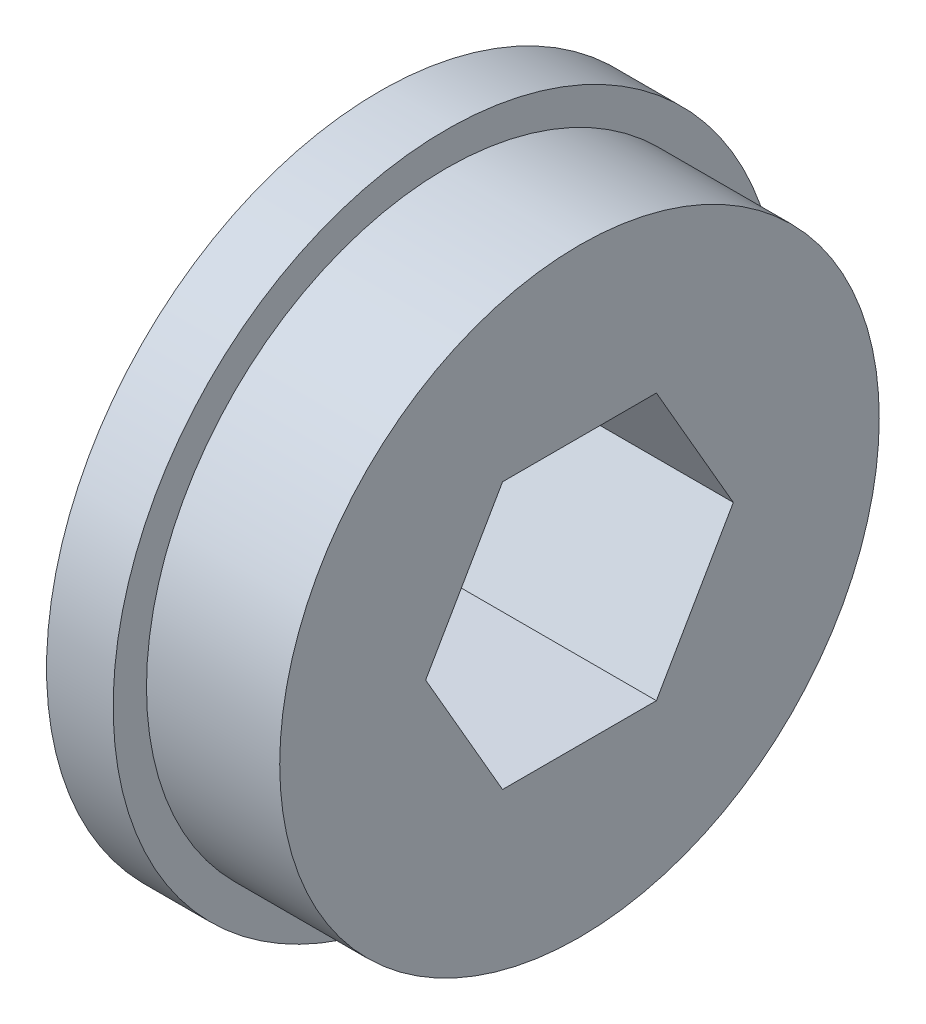
from build123d import *

# Parameters (mm, degrees)
SKETCH1_R           = 15.875
BOSS_EXTRUDE1_DEPTH = 3.175
SKETCH2_R           = 14.2875
BOSS_EXTRUDE2_DEPTH = 6.35
CUT_EXTRUDE1_DEPTH  = 10.525


with BuildPart() as part:
    # Sketch1 → Boss-Extrude1 (new body)
    with BuildSketch(Plane(origin=(0, 0, 0), x_dir=(0, 0, -1), z_dir=(1, 0, 0))):
        Circle(SKETCH1_R)
    extrude(amount=BOSS_EXTRUDE1_DEPTH)

    # Sketch2 → Boss-Extrude2 (add)
    with BuildSketch(Plane(origin=(3.175, 0, 0), x_dir=(0, 0, -1), z_dir=(1, 0, 0))):
        Circle(SKETCH2_R)
    extrude(amount=BOSS_EXTRUDE2_DEPTH)

    # Sketch3 → Cut-Extrude1 (cut, through all)
    with BuildSketch(Plane(origin=(9.525, 0, 0), x_dir=(0, 0, -1), z_dir=(1, 0, 0))):
        Polygon((7.332348419, 0), (3.666174209, 6.35), (-3.666174209, 6.35), (-7.332348419, 0), (-3.666174209, -6.35), (3.666174209, -6.35), align=None)
    extrude(amount=-CUT_EXTRUDE1_DEPTH, mode=Mode.SUBTRACT)


solid = part.part
